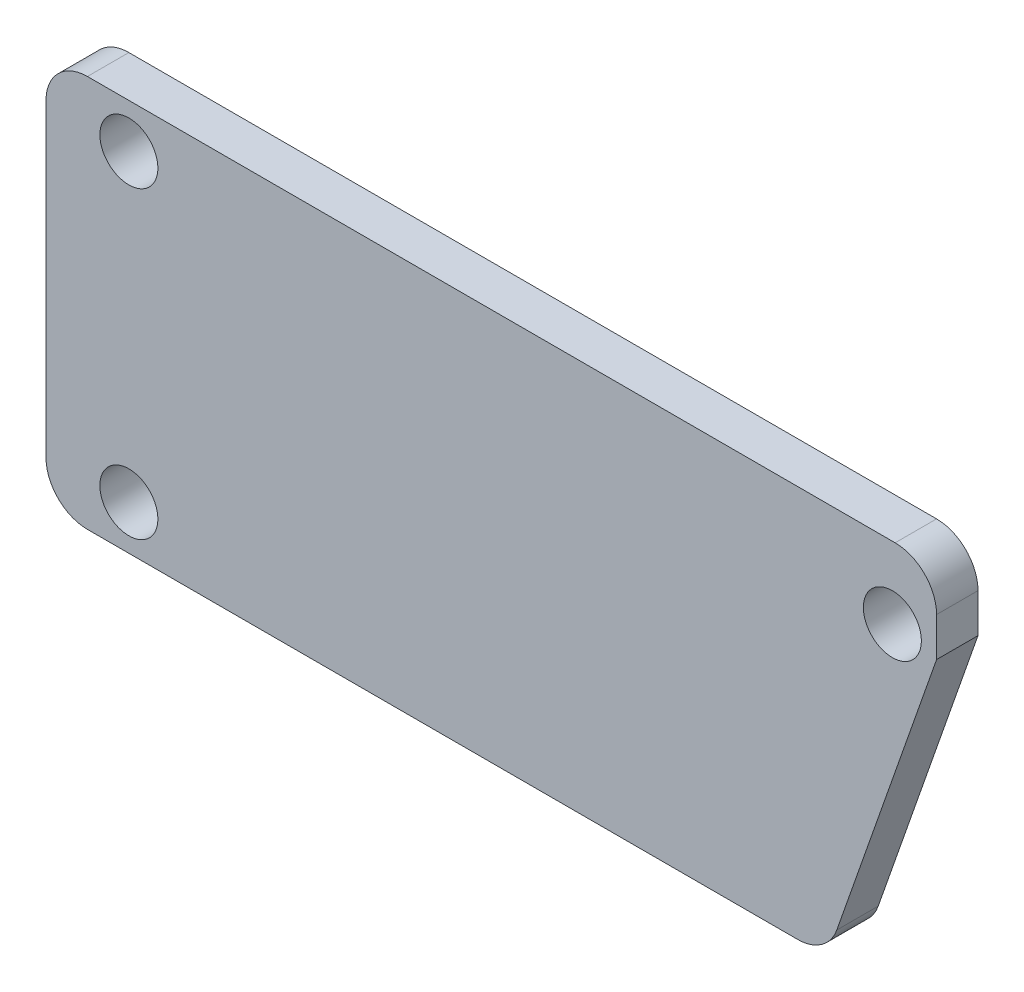
from build123d import *

# Parameters (mm, degrees)
ESQUISSE1_R        = 1.05
BOSS_EXTRU_1_DEPTH = 1.5
CONG_1_R           = 1.5
CONG_2_R           = 1.5
ESQUISSE3_W        = 2.5
ESQUISSE3_H        = 2.5
BOSS_EXTRU_2_DEPTH = 2


with BuildPart() as part:
    # Esquisse1 → Boss.-Extru.1 (new body)
    with BuildSketch(Plane.XY):
        Polygon((-8.952173913, 8.212533242), (23.287826087, 8.212533242), (23.287826087, 5.301553174), (19.32314664, -5.987466758), (-8.952173913, -5.987466758), align=None)
        with Locations((-5.952173913, -4.387466758)):
            Circle(ESQUISSE1_R, mode=Mode.SUBTRACT)
        with Locations((-5.952173913, 6.612533242)):
            Circle(ESQUISSE1_R, mode=Mode.SUBTRACT)
        with Locations((21.687826087, 5.612533242)):
            Circle(ESQUISSE1_R, mode=Mode.SUBTRACT)
    extrude(amount=BOSS_EXTRU_1_DEPTH)

    # Congé1
    cong_1_edges = [part.edges().sort_by_distance(p)[0] for p in [
        (23.287826087, 8.212533242, 0.75),
    ]]
    fillet(cong_1_edges, radius=CONG_1_R)

    # Congé2
    cong_2_edges = [part.edges().sort_by_distance(p)[0] for p in [
        (-8.952173913, 8.212533242, 0.75),
        (19.32314664, -5.987466758, 0.75),
        (-8.952173913, -5.987466758, 0.75),
    ]]
    fillet(cong_2_edges, radius=CONG_2_R)

    # Esquisse3 → Boss.-Extru.2 (add)
    with BuildSketch(Plane(origin=(0, 0, 0), x_dir=(-1, 0, 0), z_dir=(0, 0, -1))):
        with Locations((-3.957826087, 1.112533242)):
            Rectangle(ESQUISSE3_W, ESQUISSE3_H)
    extrude(amount=BOSS_EXTRU_2_DEPTH)


solid = part.part
